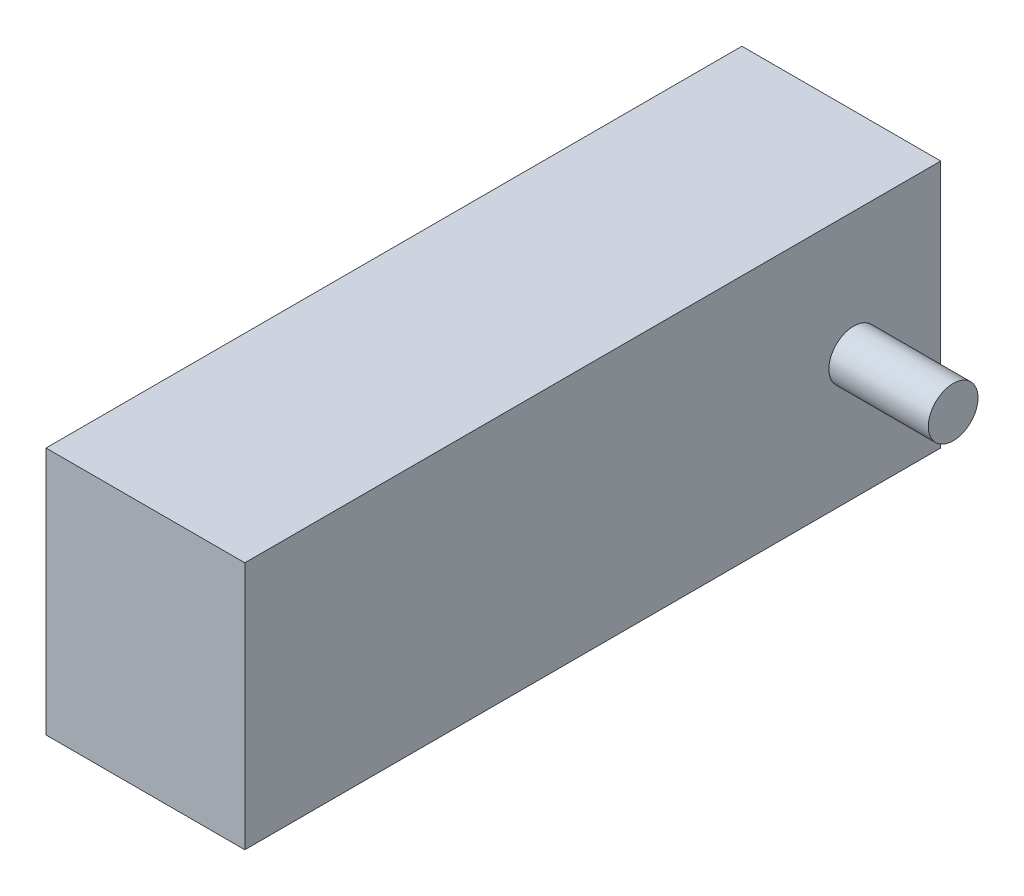
from build123d import *

# Parameters (mm, degrees)
SKETCH_1_W             = 20
SKETCH_1_H             = 70
EXTRUDE_327_DEPTH      = 25
SKETCH_2_R             = 2.5
EXTRUDE_592_DEPTH      = 10
EXTRUDE_592_DEPTH_BACK = 30


with BuildPart() as part:
    # Эскиз1 → Extrude 327 (new body)
    with BuildSketch(Plane(origin=(0, 0, 0), x_dir=(1, 0, 0), z_dir=(0, 1, 0))):
        with Locations((-10, 35)):
            Rectangle(SKETCH_1_W, SKETCH_1_H)
    extrude(amount=EXTRUDE_327_DEPTH)

    # Эскиз2 → Extrude 592 (add, two sides)
    with BuildSketch(Plane(origin=(0, 0, 0), x_dir=(0, 0, -1), z_dir=(1, 0, 0))) as extrude_592_sk:
        with Locations((61.25, 12.5)):
            Circle(SKETCH_2_R)
    extrude(amount=EXTRUDE_592_DEPTH)
    extrude(extrude_592_sk.sketch, amount=-EXTRUDE_592_DEPTH_BACK)


solid = part.part
